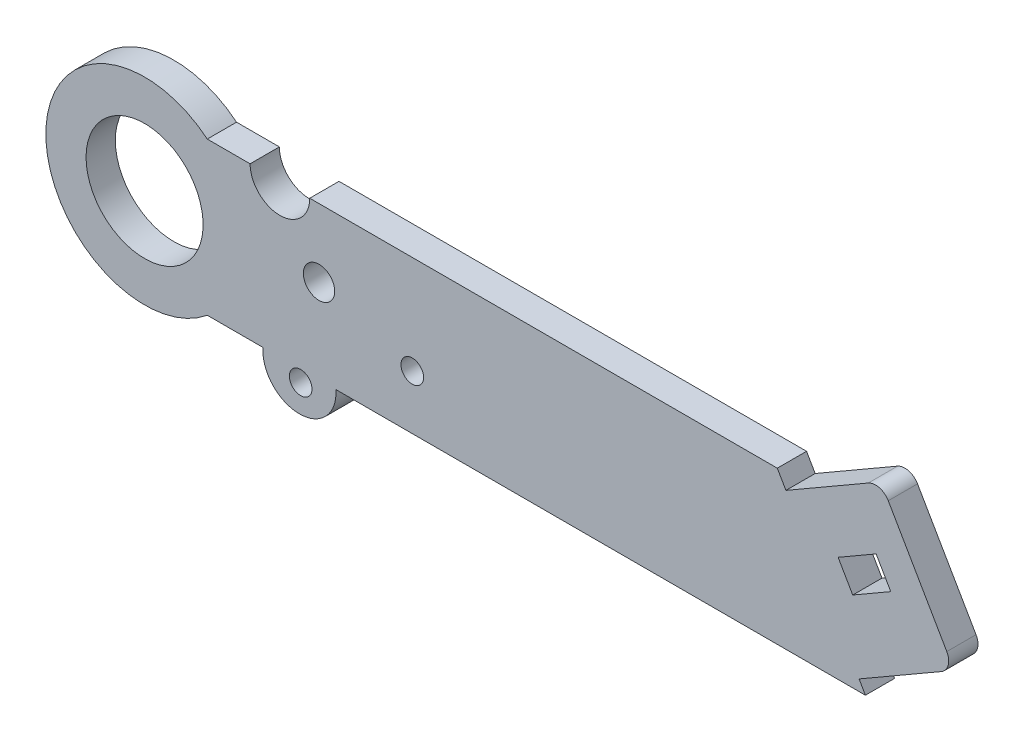
from build123d import *

# Parameters (mm, degrees)
AUFSATZ_LINEAR_AUSTRAGEN1_DEPTH = 4
SCHNITT_LINEAR_AUSTRAGEN1_REACH = 6
SKIZZE2_R                       = 8
SKIZZE2_R_2                     = 2.141321697
SCHNITT_LINEAR_START            = -4
SCHNITT_LINEAR_AUSTRAGEN2_DEPTH = 4
AUFSATZ_LINEAR_AUSTRAGEN3_DEPTH = 4
AUFSATZ_LINEAR_AUSTRAGEN4_DEPTH = 4
SCHNITT_LINEAR_AUSTRAGEN3_REACH = 6
SKIZZE6_R                       = 1.55


with BuildPart() as part:
    # Skizze1 → Aufsatz-Linear austragen1 (new body)
    with BuildSketch(Plane.XY):
        with BuildLine():
            Line((28.570550732, -10.430515814), (-71.429449268, -10.430515814))
            ThreePointArc((-71.429449268, -10.430515814), (-93.5, 0), (-71.429449268, 10.430515814))
            Line((-71.429449268, 10.430515814), (-65.575289804, 10.430515814))
            ThreePointArc((-65.575289804, 10.430515814), (-61.49939442, 6.35462043), (-57.423499036, 10.430515814))
            Line((-57.423499036, 10.430515814), (28.570550732, 10.430515814))
            ThreePointArc((28.570550732, 10.430515814), (39.001066546, 0), (28.570550732, -10.430515814))
        make_face()
    extrude(amount=AUFSATZ_LINEAR_AUSTRAGEN1_DEPTH)

    # Skizze2 → Schnitt-Linear austragen1 (cut, up to next)
    with BuildSketch(Plane.XY.offset(4), mode=Mode.PRIVATE) as schnitt_linear_austragen1_sk1:
        with Locations((-80, 0)):
            Circle(SKIZZE2_R)
    schnitt_linear_austragen1_tool1 = extrude(schnitt_linear_austragen1_sk1.sketch, amount=-SCHNITT_LINEAR_AUSTRAGEN1_REACH, mode=Mode.PRIVATE) & part.part
    add(schnitt_linear_austragen1_tool1.solids().sort_by_distance((-80, 0, 4))[0], mode=Mode.SUBTRACT)
    # Skizze2 → Schnitt-Linear austragen1 (cut, up to next)
    with BuildSketch(Plane.XY.offset(4), mode=Mode.PRIVATE) as schnitt_linear_austragen1_sk2:
        with Locations((-56.152824314, 1.105869461)):
            Circle(SKIZZE2_R_2)
    schnitt_linear_austragen1_tool2 = extrude(schnitt_linear_austragen1_sk2.sketch, amount=-SCHNITT_LINEAR_AUSTRAGEN1_REACH, mode=Mode.PRIVATE) & part.part
    add(schnitt_linear_austragen1_tool2.solids().sort_by_distance((-56.152824, 1.105869, 4))[0], mode=Mode.SUBTRACT)
    # Skizze2 → Schnitt-Linear austragen1 (cut, up to next)
    with BuildSketch(Plane.XY.offset(4), mode=Mode.PRIVATE) as schnitt_linear_austragen1_sk3:
        Polygon((14.803847577, 4.033585801), (20, 7.033585801), (22, 3.569484186), (16.803847577, 0.569484186), align=None)
    schnitt_linear_austragen1_tool3 = extrude(schnitt_linear_austragen1_sk3.sketch, amount=-SCHNITT_LINEAR_AUSTRAGEN1_REACH, mode=Mode.PRIVATE) & part.part
    add(schnitt_linear_austragen1_tool3.solids().sort_by_distance((18.401924, 3.801535, 4))[0], mode=Mode.SUBTRACT)

    # Skizze3 → Schnitt-Linear austragen2 (cut)
    with BuildSketch(Plane.XY.offset(4).offset(SCHNITT_LINEAR_START)):
        Polygon((34.526391185, 28.400642866), (53.593329276, -4.624262653), (24.786074739, -21.256138815), (17.669872981, -8.930515814), (28.92820323, -2.430515814), (18.92820323, 14.889992262), (7.669872981, 8.389992262), (5.719136647, 11.768766704), align=None)
    extrude(amount=SCHNITT_LINEAR_AUSTRAGEN2_DEPTH, mode=Mode.SUBTRACT)

    # Skizze4 → Aufsatz-Linear austragen3 (add)
    with BuildSketch(Plane.XY):
        with BuildLine():
            Line((11.204163448, 10.430515814), (18.92820323, 14.889992262))
            ThreePointArc((18.92820323, 14.889992262), (20.44584132, 15.089793107), (21.660254038, 14.157941454))
            Line((21.660254038, 14.157941454), (29.660254038, 0.301534994))
            ThreePointArc((29.660254038, 0.301534994), (29.860054883, -1.216103097), (28.92820323, -2.430515814))
            Line((28.92820323, -2.430515814), (21.502883158, 10.430515814))
            Line((21.502883158, 10.430515814), (11.204163448, 10.430515814))
        make_face()
    extrude(amount=AUFSATZ_LINEAR_AUSTRAGEN3_DEPTH)

    # Skizze5 → Aufsatz-Linear austragen4 (add)
    with BuildSketch(Plane.XY.offset(4)):
        with BuildLine():
            Line((-63.815140393, -10.430515814), (-53.843758142, -10.430515814))
            ThreePointArc((-53.843758142, -10.430515814), (-58.829449268, -15.808515814), (-63.815140393, -10.430515814))
        make_face()
    extrude(amount=-AUFSATZ_LINEAR_AUSTRAGEN4_DEPTH)

    # Skizze6 → Schnitt-Linear austragen3 (cut, up to next)
    with BuildSketch(Plane.XY.offset(4), mode=Mode.PRIVATE) as schnitt_linear_austragen3_sk1:
        with Locations((-58.663449268, -12.012515814)):
            Circle(SKIZZE6_R)
    schnitt_linear_austragen3_tool1 = extrude(schnitt_linear_austragen3_sk1.sketch, amount=-SCHNITT_LINEAR_AUSTRAGEN3_REACH, mode=Mode.PRIVATE) & part.part
    add(schnitt_linear_austragen3_tool1.solids().sort_by_distance((-58.663449, -12.012516, 4))[0], mode=Mode.SUBTRACT)
    # Skizze6 → Schnitt-Linear austragen3 (cut, up to next)
    with BuildSketch(Plane.XY.offset(4), mode=Mode.PRIVATE) as schnitt_linear_austragen3_sk2:
        with Locations((-43.404449268, -3.025515814)):
            Circle(SKIZZE6_R)
    schnitt_linear_austragen3_tool2 = extrude(schnitt_linear_austragen3_sk2.sketch, amount=-SCHNITT_LINEAR_AUSTRAGEN3_REACH, mode=Mode.PRIVATE) & part.part
    add(schnitt_linear_austragen3_tool2.solids().sort_by_distance((-43.404449, -3.025516, 4))[0], mode=Mode.SUBTRACT)


solid = part.part
